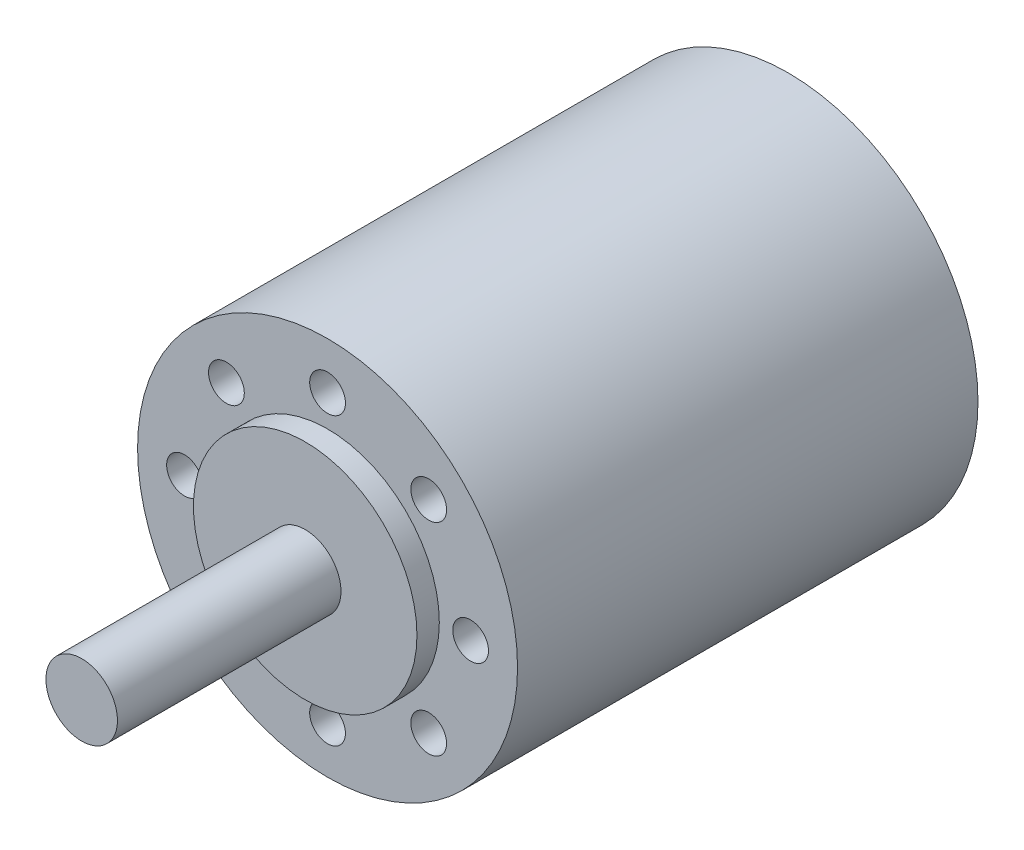
from build123d import *

# Parameters (mm, degrees)
SKETCH_1_R           = 21.25
EXTRUDE_1_DEPTH      = 51.5
SKETCH_2_R           = 1.5
EXTRUDE_2_DEPTH      = 4
SKETCH_3_R           = 8.75
CUT_EXTRUDE_1_DEPTH  = 1.5
SKETCH_4_R           = 2.5
CUT_EXTRUDE_2_DEPTH  = 6.3
SKETCH_5_R           = 2
CUT_EXTRUDE_3_DEPTH  = 7
SKETCH_7_R           = 12.5
EXTRUDE_3_DEPTH      = 2.5
SKETCH_11_R          = 4
EXTRUDE_5_DEPTH      = 25
CUT_EXTRUDE_11_DEPTH = 3.5
SKETCH_13_R          = 2
CUT_EXTRUDE_10_DEPTH = 7


with BuildPart() as part:
    # 草圖1 → 填料-伸長1 (new body)
    with BuildSketch(Plane.XY):
        Circle(SKETCH_1_R)
    extrude(amount=EXTRUDE_1_DEPTH)

    # 草圖2 → 填料-伸長2 (add)
    with BuildSketch(Plane(origin=(0, 0, 0), x_dir=(-1, 0, 0), z_dir=(0, 0, -1))):
        with Locations((0, 12.5)):
            Circle(SKETCH_2_R)
        with Locations((0, -12.5)):
            Circle(SKETCH_2_R)
    extrude(amount=EXTRUDE_2_DEPTH)

    # 草圖3 → 除料-伸長1 (cut)
    with BuildSketch(Plane(origin=(0, 0, 0), x_dir=(-1, 0, 0), z_dir=(0, 0, -1))):
        Circle(SKETCH_3_R)
    extrude(amount=-CUT_EXTRUDE_1_DEPTH, mode=Mode.SUBTRACT)

    # 草圖4 → 除料-伸長2 (cut)
    with BuildSketch(Plane(origin=(0, 0, 1.5), x_dir=(-1, 0, 0), z_dir=(0, 0, -1))):
        Circle(SKETCH_4_R)
    extrude(amount=-CUT_EXTRUDE_2_DEPTH, mode=Mode.SUBTRACT)

    # 草圖5 → 除料-伸長3 (cut)
    with BuildSketch(Plane(origin=(0, 0, 7.8), x_dir=(-1, 0, 0), z_dir=(0, 0, -1))):
        Circle(SKETCH_5_R)
    extrude(amount=-CUT_EXTRUDE_3_DEPTH, mode=Mode.SUBTRACT)

    # 草圖7 → 填料-伸長3 (add)
    with BuildSketch(Plane.XY.offset(51.5)):
        Circle(SKETCH_7_R)
    extrude(amount=EXTRUDE_3_DEPTH)

    # 草圖11 → 填料-伸長5 (add)
    with BuildSketch(Plane.XY.offset(54)):
        Circle(SKETCH_11_R)
    extrude(amount=EXTRUDE_5_DEPTH)

    # 草圖12 → 除料-伸長11 (cut)
    with BuildSketch(Plane(origin=(0, -4, 0), x_dir=(1, 0, 0), z_dir=(0, 1, 0))):
        with BuildLine():
            Line((-1.65, -74.85), (-1.65, -58.15))
            ThreePointArc((-1.65, -58.15), (0, -56.5), (1.65, -58.15))
            Line((1.65, -58.15), (1.65, -74.85))
            ThreePointArc((1.65, -74.85), (0, -76.5), (-1.65, -74.85))
        make_face()
    extrude(amount=CUT_EXTRUDE_11_DEPTH, mode=Mode.SUBTRACT)

    # 草圖13 → 除料-伸長10 (cut)
    with BuildSketch(Plane.XY.offset(51.5)):
        with Locations((16, 0)):
            Circle(SKETCH_13_R)
        with Locations((0, -16)):
            Circle(SKETCH_13_R)
        with Locations((-16, 0)):
            Circle(SKETCH_13_R)
        with Locations((0, 16)):
            Circle(SKETCH_13_R)
        with Locations((11.313708499, 11.313708499)):
            Circle(SKETCH_13_R)
        with Locations((11.313708499, -11.313708499)):
            Circle(SKETCH_13_R)
        with Locations((-11.313708499, -11.313708499)):
            Circle(SKETCH_13_R)
        with Locations((-11.313708499, 11.313708499)):
            Circle(SKETCH_13_R)
    extrude(amount=-CUT_EXTRUDE_10_DEPTH, mode=Mode.SUBTRACT)


solid = part.part
